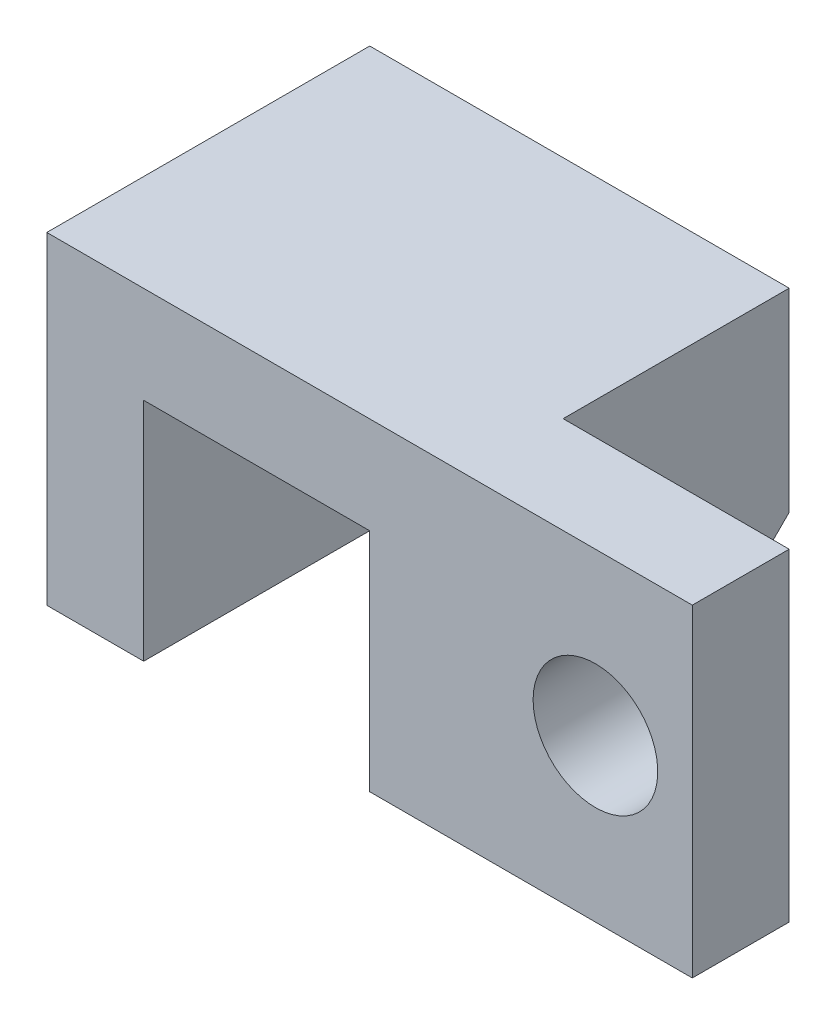
from build123d import *

# Parameters (mm, degrees)
BOSS_EXTRUDE1_DEPTH = 63.5
BOSS_EXTRUDE2_DEPTH = 63.5
SKETCH6_R           = 12.254243907
CUT_EXTRUDE1_DEPTH  = 20.05
CUT_EXTRUDE2_DEPTH  = 19.05


with BuildPart() as part:
    # Sketch3 → Boss-Extrude1 (new body)
    with BuildSketch(Plane(origin=(0, 0, 0), x_dir=(1, 0, 0), z_dir=(0, 1, 0))):
        Polygon((-130.754517968, 4.672099354), (-130.754517968, -58.827900646), (-67.254517968, -58.827900646), (-67.254517968, -39.777900646), (-111.704517968, -39.777900646), (-111.704517968, 4.672099354), align=None)
    extrude(amount=BOSS_EXTRUDE1_DEPTH)

    # Sketch4 → Boss-Extrude2 (add)
    with BuildSketch(Plane(origin=(0, 0, -4.672099354), x_dir=(-1, 0, 0), z_dir=(0, 0, -1))):
        Polygon((130.754517968, 63.5), (130.754517968, 44.443431663), (175.135531737, 44.443431663), (175.135531737, 0), (194.183522013, 0), (194.183522013, 63.5), align=None)
    extrude(amount=-BOSS_EXTRUDE2_DEPTH)

    # Sketch6 → Cut-Extrude1 (cut, through all)
    with BuildSketch(Plane(origin=(0, 0, 39.777900646), x_dir=(-1, 0, 0), z_dir=(0, 0, -1))):
        with Locations((86.304517968, 31.75)):
            Circle(SKETCH6_R)
    extrude(amount=-CUT_EXTRUDE1_DEPTH, mode=Mode.SUBTRACT)

    # Sketch8 → Cut-Extrude2 (cut)
    with BuildSketch(Plane(origin=(-111.704517968, 0, 0), x_dir=(0, 0, -1), z_dir=(1, 0, 0))):
        Polygon((4.672099354, 0), (4.672099354, 25.326198551), (-20.654099197, 0), align=None)
    extrude(amount=-CUT_EXTRUDE2_DEPTH, mode=Mode.SUBTRACT)


solid = part.part
